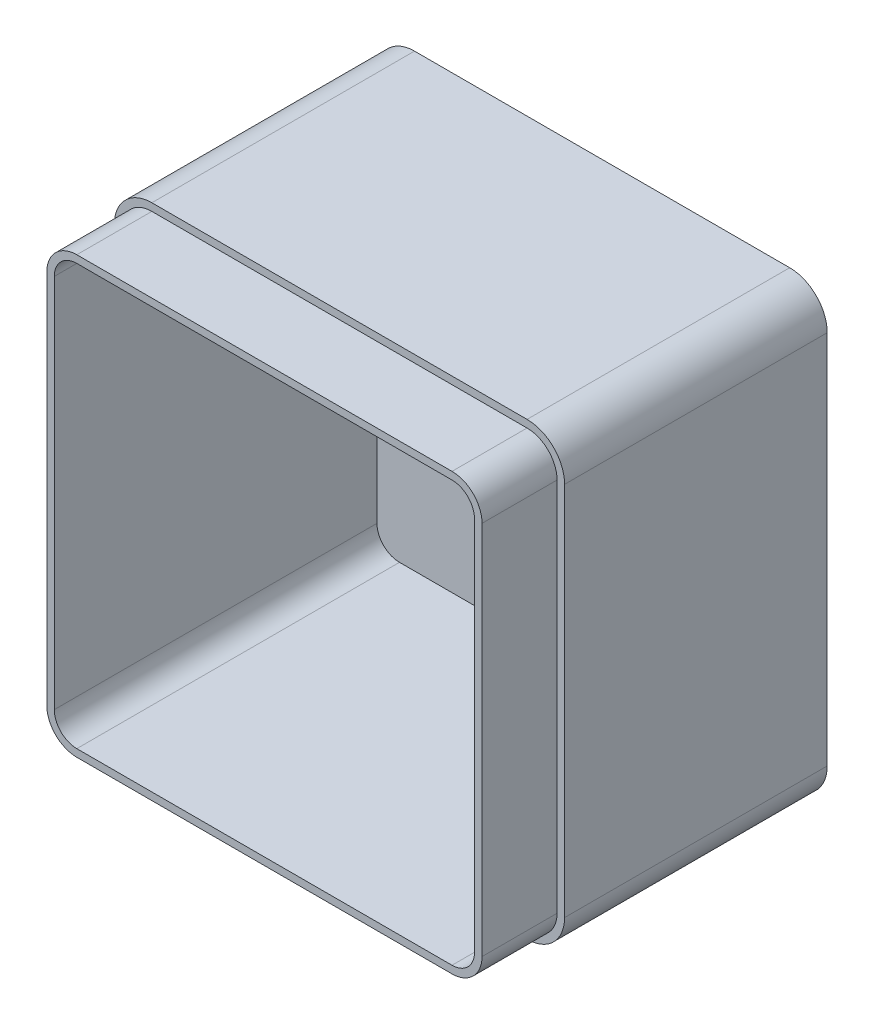
from build123d import *

# Parameters (mm, degrees)
SKETCH1_W           = 120
SKETCH1_H           = 120
BOSS_EXTRUDE1_DEPTH = 90
FILLET1_R           = 10
SHELL1_T            = -4
CUT_EXTRUDE1_DEPTH  = 20


with BuildPart() as part:
    # Sketch1 → Boss-Extrude1 (new body)
    with BuildSketch(Plane.XY):
        with Locations((60, 60)):
            Rectangle(SKETCH1_W, SKETCH1_H)
    extrude(amount=BOSS_EXTRUDE1_DEPTH)

    # Fillet1
    fillet1_edges = [part.edges().sort_by_distance(p)[0] for p in [
        (0, 120, 45),
        (120, 120, 45),
        (120, 0, 45),
        (0, 0, 45),
    ]]
    fillet(fillet1_edges, radius=FILLET1_R)

    # Shell1
    shell1_openings = [part.faces().sort_by_distance(p)[0] for p in [
        (60, 60, 90),
    ]]
    offset(amount=SHELL1_T, openings=shell1_openings, kind=Kind.INTERSECTION)

    # Sketch2 → Cut-Extrude1 (cut)
    with BuildSketch(Plane.XY.offset(90)):
        with BuildLine():
            Line((10, 0), (110, 0))
            ThreePointArc((110, 0), (117.071067812, 2.928932188), (120, 10))
            Line((120, 10), (120, 110))
            ThreePointArc((120, 110), (117.071067812, 117.071067812), (110, 120))
            Line((110, 120), (10, 120))
            ThreePointArc((10, 120), (2.928932188, 117.071067812), (0, 110))
            Line((0, 110), (0, 10))
            ThreePointArc((0, 10), (2.928932188, 2.928932188), (10, 0))
        make_face()
        with BuildLine():
            Line((10, 2), (110, 2))
            ThreePointArc((110, 2), (115.656854249, 4.343145751), (118, 10))
            Line((118, 10), (118, 110))
            ThreePointArc((118, 110), (115.656854249, 115.656854249), (110, 118))
            Line((110, 118), (10, 118))
            ThreePointArc((10, 118), (4.343145751, 115.656854249), (2, 110))
            Line((2, 110), (2, 10))
            ThreePointArc((2, 10), (4.343145751, 4.343145751), (10, 2))
        make_face(mode=Mode.SUBTRACT)
    extrude(amount=-CUT_EXTRUDE1_DEPTH, mode=Mode.SUBTRACT)


solid = part.part
